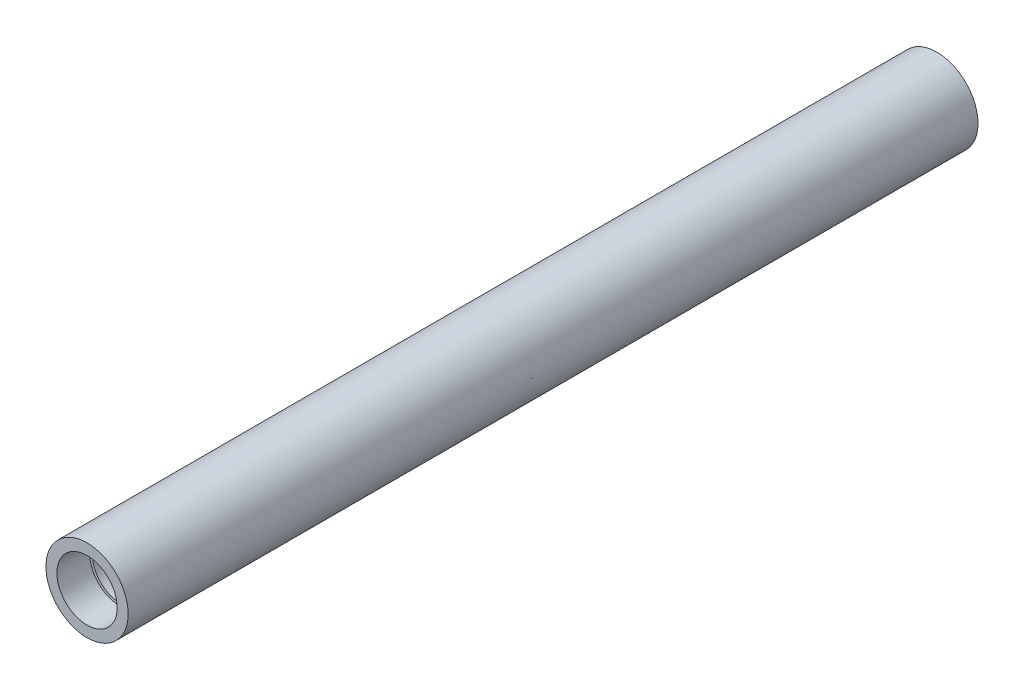
from build123d import *

# Parameters (mm, degrees)
ESQUISSE1_R             = 15
ESQUISSE1_R_2           = 10
BOSS_EXTRU_1_DEPTH      = 310
ESQUISSE2_R             = 13
ESQUISSE2_R_2           = 10
ENL_V_MAT_EXTRU_1_DEPTH = 7
ESQUISSE3_R             = 11
ESQUISSE3_R_2           = 10
ENL_V_MAT_EXTRU_2_DEPTH = 12


with BuildPart() as part:
    # Esquisse1 → Boss.-Extru.1 (new body)
    with BuildSketch(Plane.XY):
        Circle(ESQUISSE1_R)
        Circle(ESQUISSE1_R_2, mode=Mode.SUBTRACT)
    extrude(amount=BOSS_EXTRU_1_DEPTH)

    # Esquisse2 → Enlèv. mat.-Extru.1 (cut)
    with BuildSketch(Plane(origin=(0, 0, 0), x_dir=(-1, 0, 0), z_dir=(0, 0, -1))):
        Circle(ESQUISSE2_R)
        Circle(ESQUISSE2_R_2, mode=Mode.SUBTRACT)
    extrude(amount=-ENL_V_MAT_EXTRU_1_DEPTH, mode=Mode.SUBTRACT)

    # Esquisse3 → Enlèv. mat.-Extru.2 (cut)
    with BuildSketch(Plane.XY.offset(310)):
        Circle(ESQUISSE3_R)
        with Locations(Location((0, 0, 0), (0, 0, 180))):  # turned: the seam where the file's is
            Circle(ESQUISSE3_R_2, mode=Mode.SUBTRACT)
    extrude(amount=-ENL_V_MAT_EXTRU_2_DEPTH, mode=Mode.SUBTRACT)


solid = part.part
